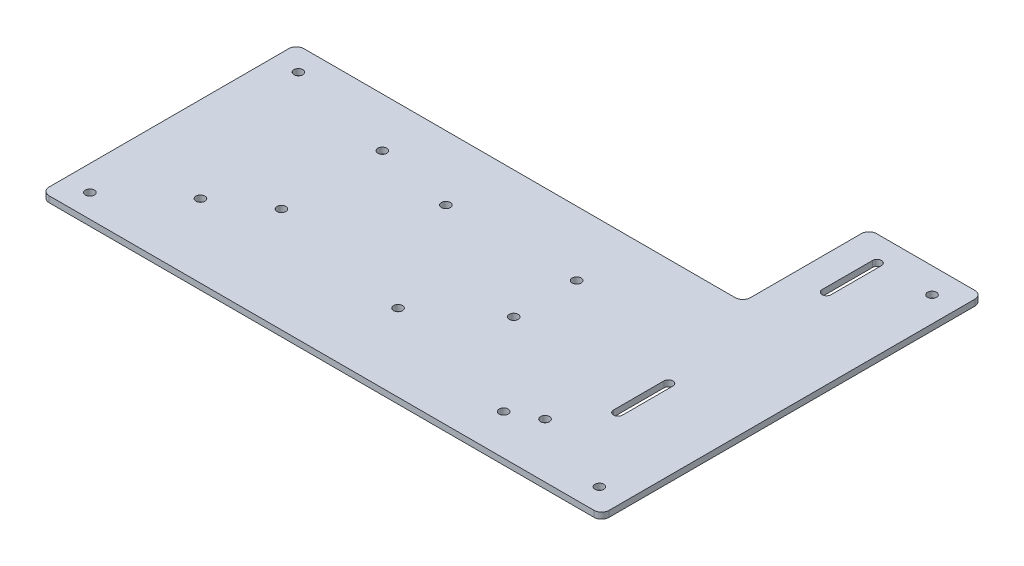
from build123d import *

# Parameters (mm, degrees)
BOSS_EXTRUDE1_DEPTH   = 3.0734
COMPRESSOR_MOUNTS_D   = 4.4958
F_8_CLEARANCE_HOLE2_D = 4.4958
FILLET1_R             = 3.81
CUT_EXTRUDE1_DEPTH    = 4.0734


with BuildPart() as part:
    # Sketch1 → Boss-Extrude1 (new body)
    with BuildSketch(Plane(origin=(0, 0, 0), x_dir=(1, 0, 0), z_dir=(0, 1, 0))):
        Polygon((0, 0), (281.94, 0), (281.94, 191.77), (224.79, 191.77), (224.79, 128.27), (0, 128.27), align=None)
    extrude(amount=BOSS_EXTRUDE1_DEPTH)

    # Compressor Mounts (through all)
    with Locations(Plane(origin=(0, 3.0734, 0), x_dir=(1, 0, 0), z_dir=(0, 1, 0))):
        with Locations((140.6525, 38.835), (107.743534656, 95.835), (173.561465344, 95.835)):
            Hole(COMPRESSOR_MOUNTS_D / 2)

    # #8 Clearance Hole2 (through all)
    with Locations(Plane(origin=(0, 3.0734, 0), x_dir=(1, 0, 0), z_dir=(0, 1, 0))):
        with Locations((12.7, 11.635), (269.24, 11.635), (269.24, 179.07), (12.7, 116.635), (173.561465344, 64.135), (140.6525, 38.835), (107.743534656, 95.835), (173.561465344, 95.835), (212.344, 20.32), (68.072, 103.505), (68.072, 52.705), (43.18, 36.83), (226.06, 27.432)):
            Hole(F_8_CLEARANCE_HOLE2_D / 2)

    # Fillet1
    fillet1_edges = [part.edges().sort_by_distance(p)[0] for p in [
        (0, 1.5367, -128.27),
        (224.79, 1.5367, -128.27),
        (224.79, 1.5367, -191.77),
        (281.94, 1.5367, -191.77),
        (281.94, 1.5367, 0),
        (0, 1.5367, 0),
    ]]
    fillet(fillet1_edges, radius=FILLET1_R)

    # Sketch7 → Cut-Extrude1 (cut, through all)
    with BuildSketch(Plane(origin=(0, 3.0734, 0), x_dir=(1, 0, 0), z_dir=(0, 1, 0))):
        with BuildLine():
            Line((243.8019, 179.07), (243.8019, 153.67))
            ThreePointArc((243.8019, 153.67), (241.554, 151.4221), (239.3061, 153.67))
            Line((239.3061, 153.67), (239.3061, 179.07))
            ThreePointArc((239.3061, 179.07), (241.554, 181.3179), (243.8019, 179.07))
        make_face()
        with BuildLine():
            Line((243.8019, 48.67), (243.8019, 74.07))
            ThreePointArc((243.8019, 74.07), (241.554, 76.3179), (239.3061, 74.07))
            Line((239.3061, 74.07), (239.3061, 48.67))
            ThreePointArc((239.3061, 48.67), (241.554, 46.4221), (243.8019, 48.67))
        make_face()
    extrude(amount=-CUT_EXTRUDE1_DEPTH, mode=Mode.SUBTRACT)


solid = part.part
